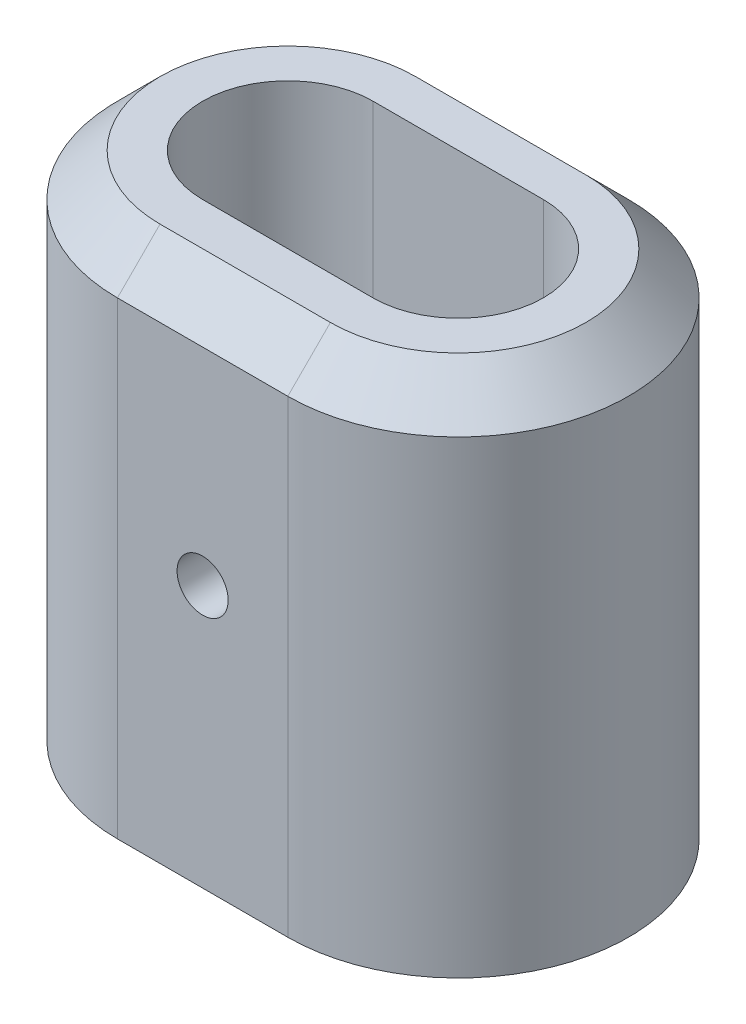
from build123d import *

# Parameters (mm, degrees)
BOSS_EXTRUDE1_DEPTH = 30
CHAMFER1_SIZE       = 5
SKETCH2_R           = 3
CUT_EXTRUDE1_DEPTH  = 41


with BuildPart() as part:
    # Sketch1 → Boss-Extrude1 (new body, symmetric)
    with BuildSketch(Plane(origin=(0, 0, 0), x_dir=(1, 0, 0), z_dir=(0, 1, 0))):
        with BuildLine():
            Line((-60, 20), (-40, 20))
            ThreePointArc((-40, 20), (-20, 0), (-40, -20))
            Line((-40, -20), (-60, -20))
            ThreePointArc((-60, -20), (-80, 0), (-60, 20))
        make_face()
        with BuildLine():
            Line((-60, 10), (-40, 10))
            ThreePointArc((-40, 10), (-30, 0), (-40, -10))
            Line((-40, -10), (-60, -10))
            ThreePointArc((-60, -10), (-70, 0), (-60, 10))
        make_face(mode=Mode.SUBTRACT)
    extrude(amount=BOSS_EXTRUDE1_DEPTH, both=True)

    # Chamfer1
    chamfer1_edges = [part.edges().sort_by_distance(p)[0] for p in [
        (-20, 30, 0),
        (-50, 30, -20),
        (-80, 30, 0),
        (-50, 30, 20),
    ]]
    chamfer(chamfer1_edges, length=CHAMFER1_SIZE)

    # Sketch2 → Cut-Extrude1 (cut, through all)
    with BuildSketch(Plane.XY.offset(20)):
        with Locations((-50, 0.75)):
            Circle(SKETCH2_R)
    extrude(amount=-CUT_EXTRUDE1_DEPTH, mode=Mode.SUBTRACT)


solid = part.part
